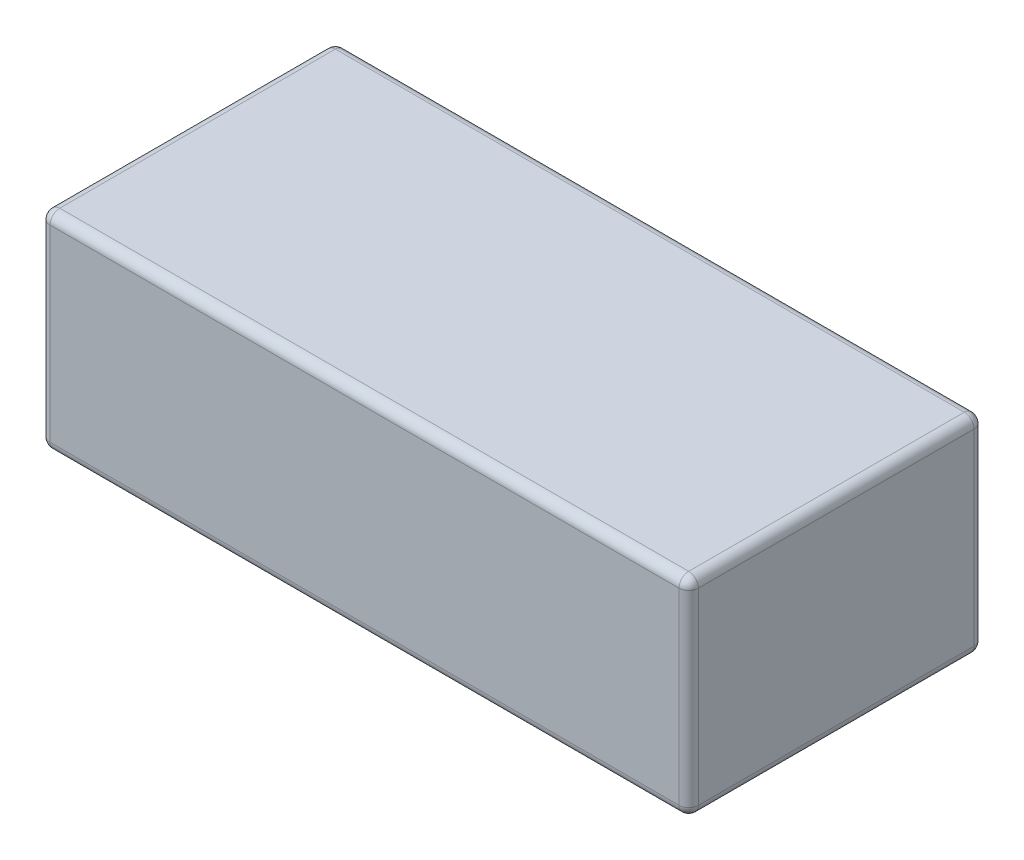
from build123d import *

# Parameters (mm, degrees)
SKETCH1_W           = 200
SKETCH1_H           = 91
BOSS_EXTRUDE1_DEPTH = 64
FILLET1_R           = 3


with BuildPart() as part:
    # Sketch1 → Boss-Extrude1 (new body)
    with BuildSketch(Plane(origin=(0, 0, 0), x_dir=(1, 0, 0), z_dir=(0, 1, 0))):
        Rectangle(SKETCH1_W, SKETCH1_H)
    extrude(amount=BOSS_EXTRUDE1_DEPTH)

    # Fillet1
    fillet1_edges = [part.edges().sort_by_distance(p)[0] for p in [
        (-100, 64, 0),
        (0, 64, 45.5),
        (100, 64, 0),
        (0, 0, 45.5),
        (-100, 0, 0),
        (0, 0, -45.5),
        (100, 0, 0),
        (0, 64, -45.5),
        (100, 32, 45.5),
        (-100, 32, 45.5),
        (-100, 32, -45.5),
        (100, 32, -45.5),
    ]]
    fillet(fillet1_edges, radius=FILLET1_R)


solid = part.part
